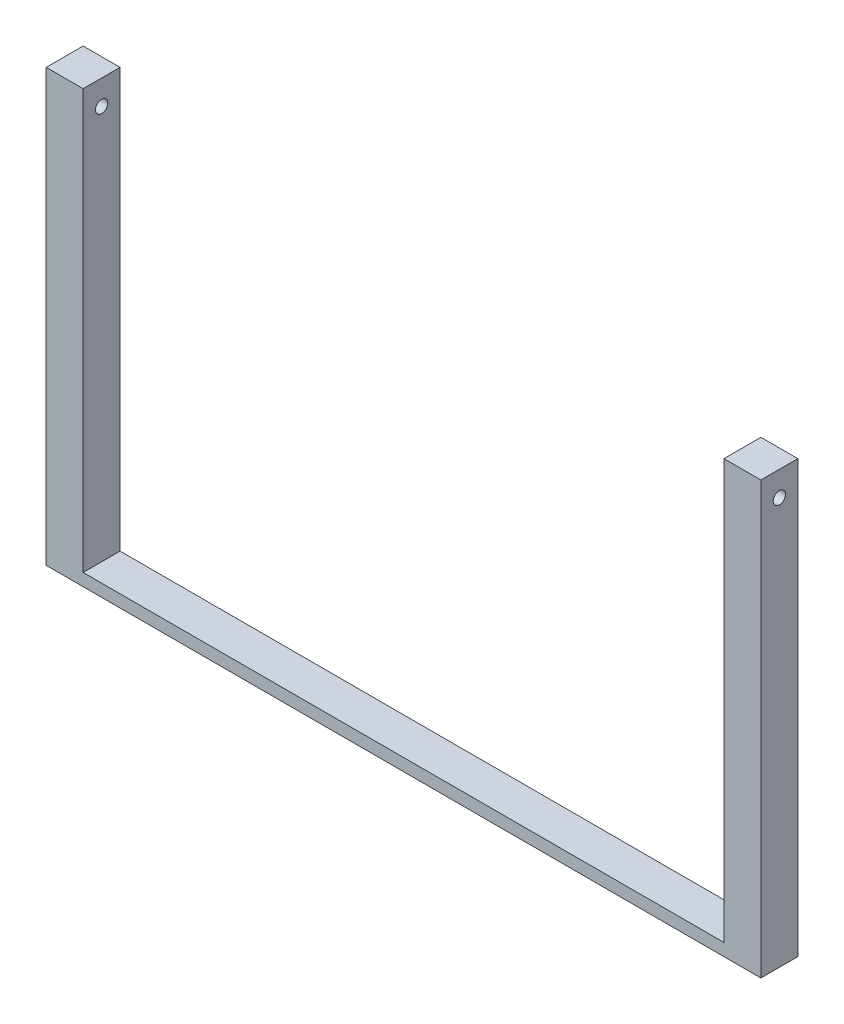
from build123d import *

# Parameters (mm, degrees)
SKETCH2_W           = 736.6
SKETCH2_H           = 38.1
BOSS_EXTRUDE1_DEPTH = 12.7
SKETCH3_W           = 38.1
SKETCH3_H           = 38.1
BOSS_EXTRUDE2_DEPTH = 431.8
SKETCH4_R           = 6.35
CUT_EXTRUDE1_DEPTH  = 737.6


with BuildPart() as part:
    # Sketch2 → Boss-Extrude1 (new body)
    with BuildSketch(Plane(origin=(0, 0, 0), x_dir=(1, 0, 0), z_dir=(0, 1, 0))):
        Rectangle(SKETCH2_W, SKETCH2_H)
    extrude(amount=BOSS_EXTRUDE1_DEPTH)

    # Sketch3 → Boss-Extrude2 (add)
    with BuildSketch(Plane(origin=(0, 12.7, 0), x_dir=(1, 0, 0), z_dir=(0, 1, 0))):
        with Locations((-349.25, 0)):
            Rectangle(SKETCH3_W, SKETCH3_H)
        with Locations((349.25, 0)):
            Rectangle(SKETCH3_W, SKETCH3_H)
    extrude(amount=BOSS_EXTRUDE2_DEPTH)

    # Sketch4 → Cut-Extrude1 (cut, through all)
    with BuildSketch(Plane(origin=(368.3, 0, 0), x_dir=(0, 0, -1), z_dir=(1, 0, 0))):
        with Locations((0, 419.1)):
            Circle(SKETCH4_R)
    extrude(amount=-CUT_EXTRUDE1_DEPTH, mode=Mode.SUBTRACT)


solid = part.part
